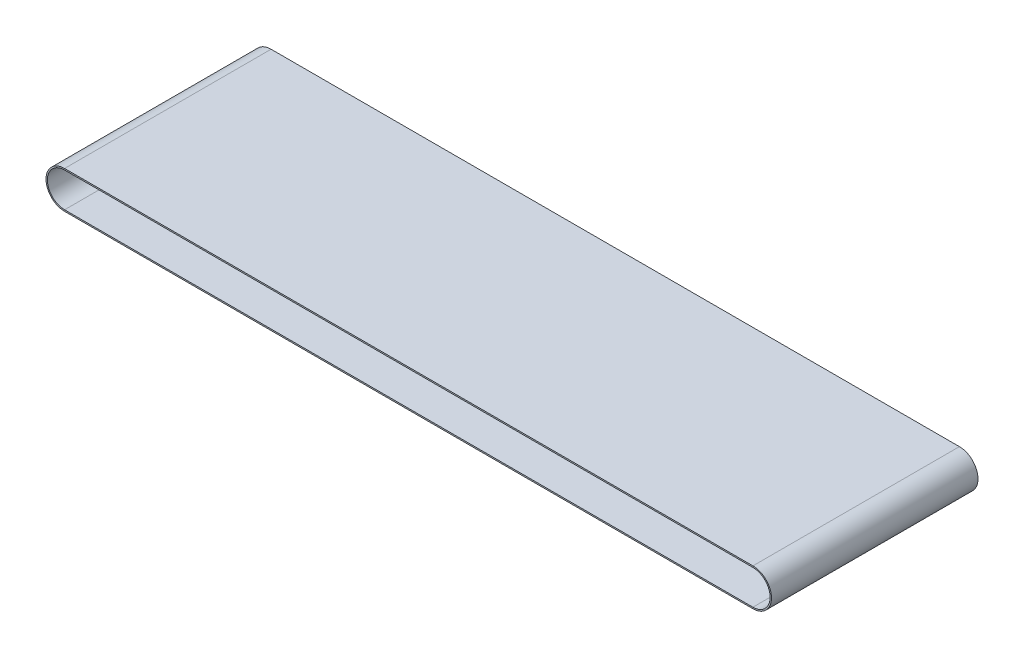
from build123d import *

# Parameters (mm, degrees)
EXTRUDE1_DEPTH      = 150
EXTRUDE1_DEPTH_BACK = 150


with BuildPart() as part:
    # Sketch1 → Extrude1 (new body, two sides)
    with BuildSketch(Plane.XY) as extrude1_sk:
        with BuildLine():
            Line((-500, 27), (500, 27))
            ThreePointArc((500, 27), (527, 0), (500, -27))
            Line((500, -27), (-500, -27))
            ThreePointArc((-500, -27), (-527, 0), (-500, 27))
        make_face()
        with BuildLine():
            Line((-500, 25), (500, 25))
            ThreePointArc((500, 25), (525, 0), (500, -25))
            Line((500, -25), (-500, -25))
            ThreePointArc((-500, -25), (-525, 0), (-500, 25))
        make_face(mode=Mode.SUBTRACT)
    extrude(amount=EXTRUDE1_DEPTH)
    extrude(extrude1_sk.sketch, amount=-EXTRUDE1_DEPTH_BACK)


solid = part.part
